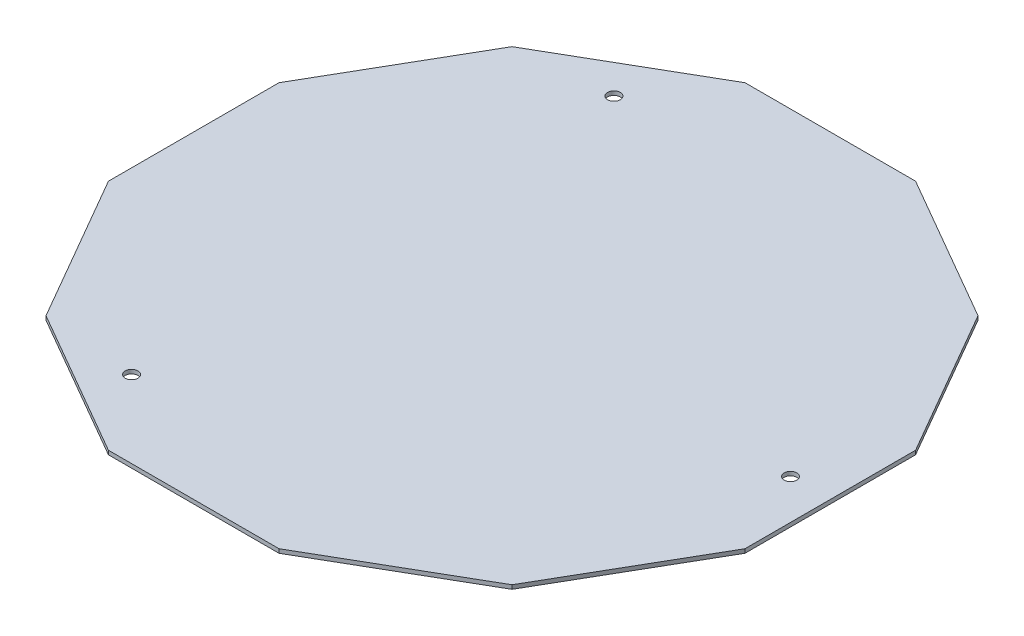
from build123d import *

# Parameters (mm, degrees)
EXTRUDE_1_DEPTH     = 1
CUT_EXTRUDE_1_REACH = 3
SKETCH_2_R          = 1.6
CUT_EXTRUDE_2_REACH = 3
SKETCH_3_R          = 1.6
CUT_EXTRUDE_3_REACH = 3
SKETCH_4_R          = 1.6


with BuildPart() as part:
    # ｽｹｯﾁ1 → ﾎﾞｽ - 押し出し1 (new body)
    with BuildSketch(Plane(origin=(0, 0, 0), x_dir=(1, 0, 0), z_dir=(0, 1, 0))):
        Polygon((-80, -21.435935394), (-58.564064606, -58.564064606), (-21.435935394, -80), (21.435935394, -80), (58.564064606, -58.564064606), (80, -21.435935394), (80, 21.435935394), (58.564064606, 58.564064606), (21.435935394, 80), (-21.435935394, 80), (-58.564064606, 58.564064606), (-80, 21.435935394), align=None)
    extrude(amount=EXTRUDE_1_DEPTH)

    # ｽｹｯﾁ2 → ｶｯﾄ - 押し出し1 (cut, up to next)
    with BuildSketch(Plane(origin=(0, 1, 0), x_dir=(1, 0, 0), z_dir=(0, 1, 0)), mode=Mode.PRIVATE) as cut_extrude_1_sk1:
        with Locations((-35, 60.621778265)):
            Circle(SKETCH_2_R)
    cut_extrude_1_tool1 = extrude(cut_extrude_1_sk1.sketch, amount=-CUT_EXTRUDE_1_REACH, mode=Mode.PRIVATE) & part.part
    add(cut_extrude_1_tool1.solids().sort_by_distance((-35, 1, -60.621778))[0], mode=Mode.SUBTRACT)

    # ｽｹｯﾁ3 → ｶｯﾄ - 押し出し2 (cut, up to next)
    with BuildSketch(Plane(origin=(0, 1, 0), x_dir=(1, 0, 0), z_dir=(0, 1, 0)), mode=Mode.PRIVATE) as cut_extrude_2_sk1:
        with Locations((-35, -60.621778265)):
            Circle(SKETCH_3_R)
    cut_extrude_2_tool1 = extrude(cut_extrude_2_sk1.sketch, amount=-CUT_EXTRUDE_2_REACH, mode=Mode.PRIVATE) & part.part
    add(cut_extrude_2_tool1.solids().sort_by_distance((-35, 1, 60.621778))[0], mode=Mode.SUBTRACT)

    # ｽｹｯﾁ4 → ｶｯﾄ - 押し出し3 (cut, up to next)
    with BuildSketch(Plane(origin=(0, 1, 0), x_dir=(1, 0, 0), z_dir=(0, 1, 0)), mode=Mode.PRIVATE) as cut_extrude_3_sk1:
        with Locations((70, 0)):
            Circle(SKETCH_4_R)
    cut_extrude_3_tool1 = extrude(cut_extrude_3_sk1.sketch, amount=-CUT_EXTRUDE_3_REACH, mode=Mode.PRIVATE) & part.part
    add(cut_extrude_3_tool1.solids().sort_by_distance((70, 1, 0))[0], mode=Mode.SUBTRACT)


solid = part.part
